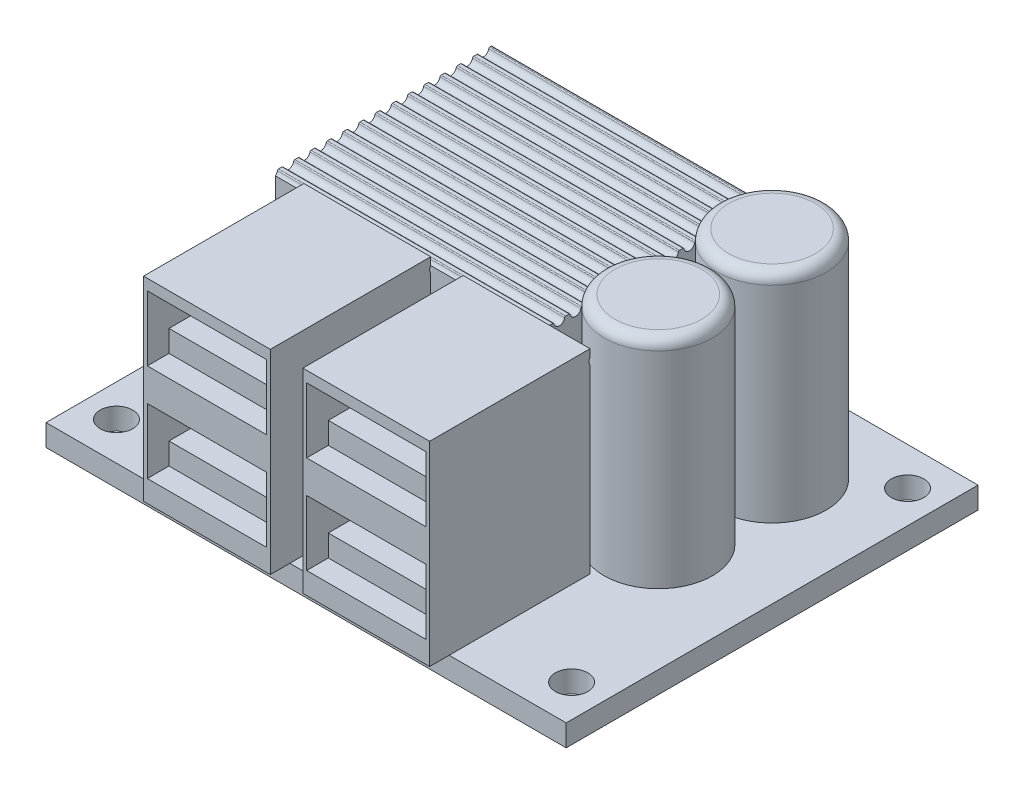
from build123d import *

# Parameters (mm, degrees)
SKETCH1_W           = 48
SKETCH1_H           = 38
SKETCH1_R           = 1.5
BOSS_EXTRUDE1_DEPTH = 2
SKETCH2_W           = 11.7
SKETCH2_H           = 14.8
BOSS_EXTRUDE2_DEPTH = 18
SKETCH3_W           = 11
SKETCH3_H           = 6
CUT_EXTRUDE1_DEPTH  = 13
SKETCH4_W           = 11
SKETCH4_H           = 11
BOSS_EXTRUDE3_DEPTH = 2
SKETCH5_W           = 11
SKETCH5_H           = 11
BOSS_EXTRUDE4_DEPTH = 2
SKETCH6_W           = 25
SKETCH6_H           = 20
BOSS_EXTRUDE5_DEPTH = 17
SKETCH7_R           = 0.5
CUT_EXTRUDE2_DEPTH  = 41.536312966
FILLET1_R           = 0.1
SKETCH8_R           = 5
BOSS_EXTRUDE6_DEPTH = 20
FILLET2_R           = 1
SKETCH9_W           = 5
SKETCH9_H           = 15
BOSS_EXTRUDE7_DEPTH = 7
CHAMFER1_SIZE       = 2
SKETCH10_R          = 1
CUT_EXTRUDE3_DEPTH  = 1


with BuildPart() as part:
    # Sketch1 → Boss-Extrude1 (new body)
    with BuildSketch(Plane(origin=(0, 0, 0), x_dir=(1, 0, 0), z_dir=(0, 1, 0))):
        Rectangle(SKETCH1_W, SKETCH1_H)
        with Locations((-21, 15.5)):
            Circle(SKETCH1_R, mode=Mode.SUBTRACT)
        with Locations((-21, -15.5)):
            Circle(SKETCH1_R, mode=Mode.SUBTRACT)
        with Locations((21, -15.5)):
            Circle(SKETCH1_R, mode=Mode.SUBTRACT)
        with Locations((21, 15.5)):
            Circle(SKETCH1_R, mode=Mode.SUBTRACT)
    extrude(amount=BOSS_EXTRUDE1_DEPTH)

    # Sketch2 → Boss-Extrude2 (add)
    with BuildSketch(Plane(origin=(0, 2, 0), x_dir=(1, 0, 0), z_dir=(0, 1, 0))):
        with Locations((-7.35, -13.4)):
            Rectangle(SKETCH2_W, SKETCH2_H)
    boss_extrude2 = extrude(amount=BOSS_EXTRUDE2_DEPTH)

    # Sketch3 → Cut-Extrude1 (cut)
    with BuildSketch(Plane.XY.offset(20.8)):
        with Locations((-7.35, 16)):
            Rectangle(SKETCH3_W, SKETCH3_H)
        with Locations((-7.35, 7)):
            Rectangle(SKETCH3_W, SKETCH3_H)
    cut_extrude1 = extrude(amount=-CUT_EXTRUDE1_DEPTH, mode=Mode.SUBTRACT)

    # Sketch4 → Boss-Extrude3 (add)
    with BuildSketch(Plane(origin=(0, 13, 0), x_dir=(1, 0, 0), z_dir=(0, 1, 0))):
        with Locations((-7.35, -13.3)):
            Rectangle(SKETCH4_W, SKETCH4_H)
    boss_extrude3 = extrude(amount=BOSS_EXTRUDE3_DEPTH)

    # Sketch5 → Boss-Extrude4 (add)
    with BuildSketch(Plane(origin=(0, 4, 0), x_dir=(1, 0, 0), z_dir=(0, 1, 0))):
        with Locations((-7.35, -13.3)):
            Rectangle(SKETCH5_W, SKETCH5_H)
    boss_extrude4 = extrude(amount=BOSS_EXTRUDE4_DEPTH)

    # Mirror1: Boss-Extrude2, Cut-Extrude1, Boss-Extrude3, Boss-Extrude4 across plane
    add(boss_extrude2.mirror(Plane(origin=(0, 0, 0), x_dir=(0, 0, 1), z_dir=(1, 0, 0))))
    add(cut_extrude1.mirror(Plane(origin=(0, 0, 0), x_dir=(0, 0, 1), z_dir=(1, 0, 0))), mode=Mode.SUBTRACT)
    add(boss_extrude3.mirror(Plane(origin=(0, 0, 0), x_dir=(0, 0, 1), z_dir=(1, 0, 0))))
    add(boss_extrude4.mirror(Plane(origin=(0, 0, 0), x_dir=(0, 0, 1), z_dir=(1, 0, 0))))

    # Sketch6 → Boss-Extrude5 (add)
    with BuildSketch(Plane(origin=(0, 2, 0), x_dir=(1, 0, 0), z_dir=(0, 1, 0))):
        with Locations((-4.036312966, 4.7)):
            Rectangle(SKETCH6_W, SKETCH6_H)
    extrude(amount=BOSS_EXTRUDE5_DEPTH)

    # Sketch7 → Cut-Extrude2 (cut, through all)
    with BuildSketch(Plane.ZY.offset(16.536312966)):
        with Locations((-13.901253827, 19)):
            Circle(SKETCH7_R)
        with Locations((-12.401253827, 19)):
            Circle(SKETCH7_R)
        with Locations((-10.901253827, 19)):
            Circle(SKETCH7_R)
        with Locations((-9.401253827, 19)):
            Circle(SKETCH7_R)
        with Locations((-7.901253827, 19)):
            Circle(SKETCH7_R)
        with Locations((-6.401253827, 19)):
            Circle(SKETCH7_R)
        with Locations((-4.901253827, 19)):
            Circle(SKETCH7_R)
        with Locations((-3.401253827, 19)):
            Circle(SKETCH7_R)
        with Locations((-1.901253827, 19)):
            Circle(SKETCH7_R)
        with Locations((-0.401253827, 19)):
            Circle(SKETCH7_R)
        with Locations((1.098746173, 19)):
            Circle(SKETCH7_R)
        with Locations((2.598746173, 19)):
            Circle(SKETCH7_R)
        with Locations((4.098746173, 19)):
            Circle(SKETCH7_R)
        with Locations((5.598746173, 19)):
            Circle(SKETCH7_R)
    extrude(amount=-CUT_EXTRUDE2_DEPTH, mode=Mode.SUBTRACT)

    # Fillet1
    fillet1_edges = [part.edges().sort_by_distance(p)[0] for p in [
        (-4.036312966, 19, -14.7),
        (-4.036312966, 19, -13.401253827),
        (-4.036312966, 19, -14.401253827),
        (-4.036312966, 19, -11.901253827),
        (-4.036312966, 19, -12.901253827),
        (-4.036312966, 19, -10.401253827),
        (-4.036312966, 19, -11.401253827),
        (-4.036312966, 19, -8.901253827),
        (-4.036312966, 19, -9.901253827),
        (-4.036312966, 19, -7.401253827),
        (-4.036312966, 19, -8.401253827),
        (-4.036312966, 19, -5.901253827),
        (-4.036312966, 19, -6.901253827),
        (-4.036312966, 19, -4.401253827),
        (-4.036312966, 19, -5.401253827),
        (-4.036312966, 19, -2.901253827),
        (-4.036312966, 19, -3.901253827),
        (-4.036312966, 19, -1.401253827),
        (-4.036312966, 19, -2.401253827),
        (-4.036312966, 19, 0.098746173),
        (-4.036312966, 19, -0.901253827),
        (-4.036312966, 19, 1.598746173),
        (-4.036312966, 19, 0.598746173),
        (-4.036312966, 19, 3.098746173),
        (-4.036312966, 19, 2.098746173),
        (-4.036312966, 19, 4.598746173),
        (-4.036312966, 19, 3.598746173),
        (-4.036312966, 19, 5.098746173),
    ]]
    fillet(fillet1_edges, radius=FILLET1_R)

    # Sketch8 → Boss-Extrude6 (add)
    with BuildSketch(Plane(origin=(0, 2, 0), x_dir=(1, 0, 0), z_dir=(0, 1, 0))):
        with Locations((14, 10)):
            Circle(SKETCH8_R)
        with Locations((14, -0.5)):
            Circle(SKETCH8_R)
    extrude(amount=BOSS_EXTRUDE6_DEPTH)

    # Fillet2
    fillet2_edges = [part.edges().sort_by_distance(p)[0] for p in [
        (9, 22, -10),
        (9, 22, 0.5),
    ]]
    fillet(fillet2_edges, radius=FILLET2_R)

    # Sketch9 → Boss-Extrude7 (add)
    with BuildSketch(Plane(origin=(0, 2, 0), x_dir=(1, 0, 0), z_dir=(0, 1, 0))):
        with Locations((-20.760712337, -0.5)):
            Rectangle(SKETCH9_W, SKETCH9_H)
    extrude(amount=BOSS_EXTRUDE7_DEPTH)

    # Chamfer1
    chamfer1_edges = [part.edges().sort_by_distance(p)[0] for p in [
        (-18.260712337, 9, 0.5),
    ]]
    chamfer(chamfer1_edges, length=CHAMFER1_SIZE)

    # Sketch10 → Cut-Extrude3 (cut)
    with BuildSketch(Plane(origin=(0, 9, 0), x_dir=(1, 0, 0), z_dir=(0, 1, 0))):
        with Locations((-21.952606412, 3.5)):
            Circle(SKETCH10_R)
        with Locations((-21.952606412, -4.5)):
            Circle(SKETCH10_R)
    extrude(amount=-CUT_EXTRUDE3_DEPTH, mode=Mode.SUBTRACT)


solid = part.part
